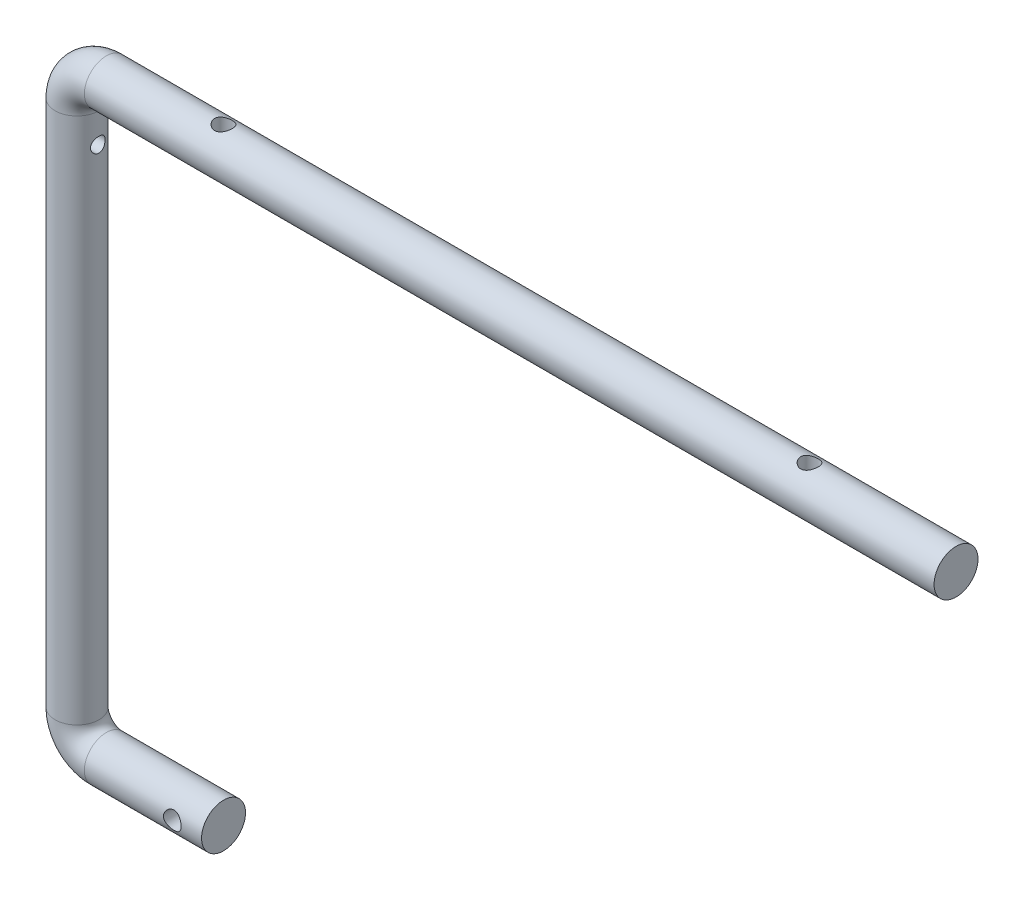
from build123d import *

# Parameters (mm, degrees)
SKETCH_2_R               = 7.5
CUT_EXTRUDE_1_DEPTH      = 10
CUT_EXTRUDE_1_DEPTH_BACK = 10
SKETCH_3_R               = 3
SKETCH_4_R               = 3
CUT_EXTRUDE_2_DEPTH      = 175
SKETCH_5_R               = 2.5
CUT_EXTRUDE_3_DEPTH      = 325.980768805


with BuildPart() as part:
    # 扫描1: sweep along a path in 草图1
    with BuildLine(Plane.XY) as sweep_1_path:
        Line((0, 0), (-40, 0))
        ThreePointArc((-40, 0), (-47.071067812, 2.928932188), (-50, 10))
        Line((-50, 10), (-50, 190))
        ThreePointArc((-50, 190), (-47.071067812, 197.071067812), (-40, 200))
        Line((-40, 200), (250, 200))
    # 草图2 → 扫描1 (sweep)
    with BuildSketch(Plane(origin=(0, 0, 0), x_dir=(0, 0, -1), z_dir=(1, 0, 0))):
        Circle(SKETCH_2_R)
    sweep(path=sweep_1_path.line)

    # 草图3 → 切除-拉伸1 (cut, two sides: drawn at the far end of the back side and taken through both)
    with BuildSketch(Plane.XY.offset(-CUT_EXTRUDE_1_DEPTH_BACK)):
        with Locations((-10, 0)):
            Circle(SKETCH_3_R)
    extrude(amount=CUT_EXTRUDE_1_DEPTH + CUT_EXTRUDE_1_DEPTH_BACK, mode=Mode.SUBTRACT)

    # 草图4 → 切除-拉伸2 (cut)
    with BuildSketch(Plane(origin=(0, 50, 0), x_dir=(1, 0, 0), z_dir=(0, 1, 0))):
        with Locations((200, 0)):
            Circle(SKETCH_4_R)
        Circle(SKETCH_4_R)
    extrude(amount=CUT_EXTRUDE_2_DEPTH, mode=Mode.SUBTRACT)

    # 草图5 → 切除-拉伸3 (cut, through all)
    with BuildSketch(Plane(origin=(0, 0, 0), x_dir=(0, 0, -1), z_dir=(1, 0, 0))):
        with Locations((0, 180)):
            Circle(SKETCH_5_R)
    extrude(amount=-CUT_EXTRUDE_3_DEPTH, mode=Mode.SUBTRACT)


solid = part.part
